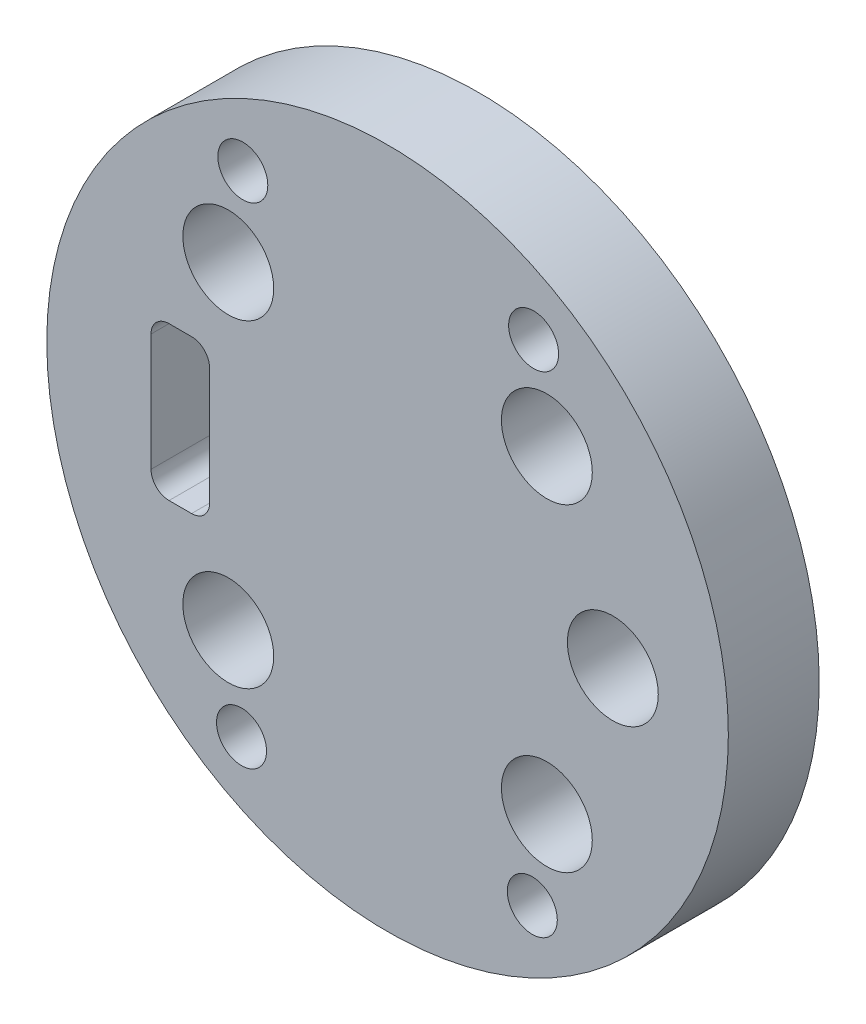
from build123d import *

# Parameters (mm, degrees)
SKETCH_1_R          = 37.5
EXTRUDE_1_DEPTH     = 10
SKETCH_2_R          = 5
CUT_EXTRUDE_1_DEPTH = 10
SKETCH_4_R          = 2.75
CUT_EXTRUDE_2_DEPTH = 10


with BuildPart() as part:
    # 草图1 → 凸台-拉伸1 (new body)
    with BuildSketch(Plane.XY):
        Circle(SKETCH_1_R)
        with BuildLine():
            ThreePointArc((-20.75113276, -17.528548354), (-17.528548354, -14.305963949), (-14.305963949, -17.528548354))
            ThreePointArc((-14.305963949, -17.528548354), (-17.528548354, -20.75113276), (-20.75113276, -17.528548354))
        make_face(mode=Mode.SUBTRACT)
        with BuildLine():
            ThreePointArc((14.305963949, -17.528548354), (17.528548354, -14.305963949), (20.75113276, -17.528548354))
            ThreePointArc((20.75113276, -17.528548354), (17.528548354, -20.75113276), (14.305963949, -17.528548354))
        make_face(mode=Mode.SUBTRACT)
        with BuildLine():
            Line((-24.045437487, 8.428297676), (-21.566526406, 8.428297676))
            ThreePointArc((-21.566526406, 8.428297676), (-20.68362959, 8.220920288), (-19.985383241, 7.642159365))
            ThreePointArc((-19.985383241, 7.642159365), (-19.686578169, 7.076512396), (-19.583397541, 6.445168811))
            Line((-19.583397541, 6.445168811), (-19.583397541, -6.445168811))
            ThreePointArc((-19.583397541, -6.445168811), (-20.164242538, -7.847452679), (-21.566526406, -8.428297676))
            Line((-21.566526406, -8.428297676), (-24.045437487, -8.428297676))
            ThreePointArc((-24.045437487, -8.428297676), (-25.447721356, -7.847452679), (-26.028566352, -6.445168811))
            Line((-26.028566352, -6.445168811), (-26.028566352, 6.445168811))
            ThreePointArc((-26.028566352, 6.445168811), (-25.447721356, 7.847452679), (-24.045437487, 8.428297676))
        make_face(mode=Mode.SUBTRACT)
        with BuildLine():
            ThreePointArc((-20.75113276, 17.528548354), (-17.528548354, 20.75113276), (-14.305963949, 17.528548354))
            ThreePointArc((-14.305963949, 17.528548354), (-17.528548354, 14.305963949), (-20.75113276, 17.528548354))
        make_face(mode=Mode.SUBTRACT)
        with BuildLine():
            ThreePointArc((14.305963949, 17.528548354), (17.528548354, 20.75113276), (20.75113276, 17.528548354))
            ThreePointArc((20.75113276, 17.528548354), (17.528548354, 14.305963949), (14.305963949, 17.528548354))
        make_face(mode=Mode.SUBTRACT)
        with BuildLine():
            ThreePointArc((21.814417514, 0), (24.789110812, 2.974693297), (27.763804109, 0))
            ThreePointArc((27.763804109, 0), (24.789110812, -2.974693297), (21.814417514, 0))
        make_face(mode=Mode.SUBTRACT)
    extrude(amount=EXTRUDE_1_DEPTH)

    # 草图2 → 切除-拉伸1 (cut)
    with BuildSketch(Plane.XY.offset(10)):
        with Locations((-17.528548354, 17.528548354)):
            Circle(SKETCH_2_R)
        with BuildLine():
            ThreePointArc((-20.75113276, 17.528548354), (-17.528548354, 14.305963949), (-14.305963949, 17.528548354))
            ThreePointArc((-14.305963949, 17.528548354), (-17.528548354, 20.75113276), (-20.75113276, 17.528548354))
        make_face(mode=Mode.SUBTRACT)
        with Locations((17.528548354, 17.528548354)):
            Circle(SKETCH_2_R)
        with BuildLine():
            ThreePointArc((20.75113276, 17.528548354), (17.528548354, 20.75113276), (14.305963949, 17.528548354))
            ThreePointArc((14.305963949, 17.528548354), (17.528548354, 14.305963949), (20.75113276, 17.528548354))
        make_face(mode=Mode.SUBTRACT)
        with Locations((-17.528548354, -17.528548354)):
            Circle(SKETCH_2_R)
        with BuildLine():
            ThreePointArc((-20.75113276, -17.528548354), (-17.528548354, -20.75113276), (-14.305963949, -17.528548354))
            ThreePointArc((-14.305963949, -17.528548354), (-17.528548354, -14.305963949), (-20.75113276, -17.528548354))
        make_face(mode=Mode.SUBTRACT)
        with Locations((17.528548354, -17.528548354)):
            Circle(SKETCH_2_R)
        with BuildLine():
            ThreePointArc((14.305963949, -17.528548354), (17.528548354, -20.75113276), (20.75113276, -17.528548354))
            ThreePointArc((20.75113276, -17.528548354), (17.528548354, -14.305963949), (14.305963949, -17.528548354))
        make_face(mode=Mode.SUBTRACT)
        with Locations((24.789110812, 0)):
            Circle(SKETCH_2_R)
        with BuildLine():
            ThreePointArc((21.814417514, 0), (24.789110812, -2.974693297), (27.763804109, 0))
            ThreePointArc((27.763804109, 0), (24.789110812, 2.974693297), (21.814417514, 0))
        make_face(mode=Mode.SUBTRACT)
    extrude(amount=-CUT_EXTRUDE_1_DEPTH, mode=Mode.SUBTRACT)

    # 草图4 → 切除-拉伸2 (cut)
    with BuildSketch(Plane.XY.offset(10)):
        with Locations((-16.071064876, -26.957760919)):
            Circle(SKETCH_4_R)
        with Locations((15.928824109, -27.042051743)):
            Circle(SKETCH_4_R)
        with Locations((16.071064876, 26.957760919)):
            Circle(SKETCH_4_R)
        with Locations((-15.928824109, 27.042051743)):
            Circle(SKETCH_4_R)
    extrude(amount=-CUT_EXTRUDE_2_DEPTH, mode=Mode.SUBTRACT)


solid = part.part
